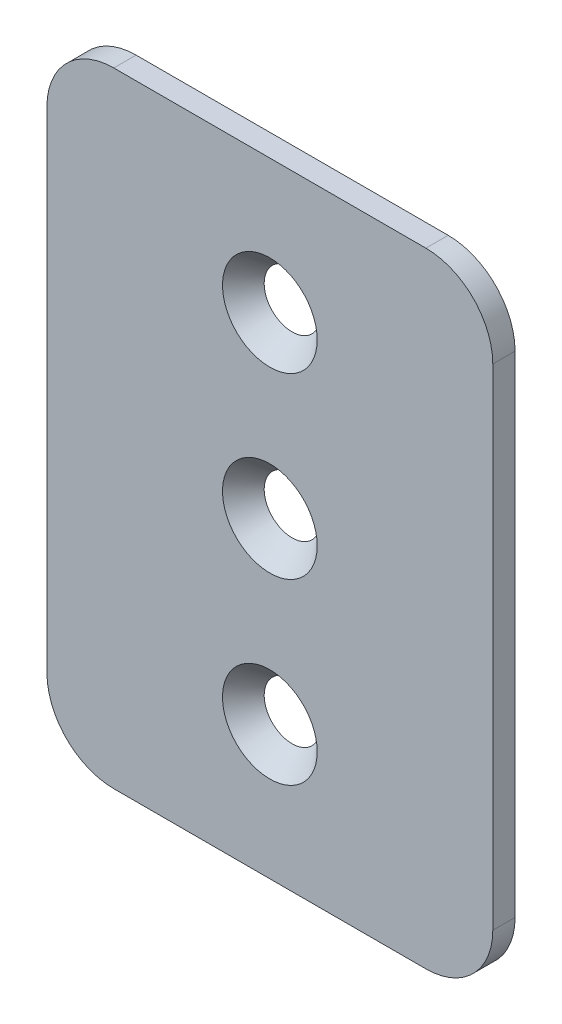
from build123d import *

# Parameters (mm, degrees)
SKETCH1_R                                    = 2.5527
BOSS_EXTRUDE1_DEPTH                          = 3.175
CSK_FOR_1_4_FLAT_HEAD_SOCKET_CAP_SCR_2_COUNT = 2
CSK_FOR_1_4_FLAT_HEAD_SOCKET_CAP_SCR_2_PITCH = 25.4
CSK_FOR_1_4_FLAT_HEAD_SOCKET_CAP_SCR_3_COUNT = 2
CSK_FOR_1_4_FLAT_HEAD_SOCKET_CAP_SCR_3_PITCH = 50.8


with BuildPart() as part:
    # Sketch1 → Boss-Extrude1 (new body)
    with BuildSketch(Plane.XY):
        with BuildLine():
            Line((-22.225, 44.45), (22.225, 44.45))
            ThreePointArc((22.225, 44.45), (28.960192091, 41.660192091), (31.75, 34.925))
            Line((31.75, 34.925), (31.75, -34.925))
            ThreePointArc((31.75, -34.925), (28.960192091, -41.660192091), (22.225, -44.45))
            Line((22.225, -44.45), (-22.225, -44.45))
            ThreePointArc((-22.225, -44.45), (-28.960192091, -41.660192091), (-31.75, -34.925))
            Line((-31.75, -34.925), (-31.75, 34.925))
            ThreePointArc((-31.75, 34.925), (-28.960192091, 41.660192091), (-22.225, 44.45))
        make_face()
        with Locations((0, 25.4)):
            Circle(SKETCH1_R, mode=Mode.SUBTRACT)
        Circle(SKETCH1_R, mode=Mode.SUBTRACT)
        with Locations((0, -25.4)):
            Circle(SKETCH1_R, mode=Mode.SUBTRACT)
    extrude(amount=BOSS_EXTRUDE1_DEPTH)

    # Sketch2 → CSK for 1/4 Flat Head Socket Cap Screw1 (revolve, cut)
    with BuildSketch(Plane(origin=(0, 25.4, 3.175), x_dir=(0, -1, 0), z_dir=(1, 0, 0))):
        Polygon((0, 0), (0, 3.175), (3.3782, 3.175), (3.3782, 3.871564875), (6.7437, 0), align=None)
    csk_for_1_4_flat_head_socket_cap_screw1 = revolve(axis=Axis((0, 25.4, 9.525), (0, 0, -1)), mode=Mode.SUBTRACT)

    # CSK for 1_4 Flat Head Socket Cap Scr 2: CSK for 1/4 Flat Head Socket Cap Screw1 ×2
    with Locations(*[(0, -i * CSK_FOR_1_4_FLAT_HEAD_SOCKET_CAP_SCR_2_PITCH, 0) for i in range(1, CSK_FOR_1_4_FLAT_HEAD_SOCKET_CAP_SCR_2_COUNT)]):
        add(csk_for_1_4_flat_head_socket_cap_screw1, mode=Mode.SUBTRACT)

    # CSK for 1_4 Flat Head Socket Cap Scr 3: CSK for 1/4 Flat Head Socket Cap Screw1 ×2
    with Locations(*[(0, -i * CSK_FOR_1_4_FLAT_HEAD_SOCKET_CAP_SCR_3_PITCH, 0) for i in range(1, CSK_FOR_1_4_FLAT_HEAD_SOCKET_CAP_SCR_3_COUNT)]):
        add(csk_for_1_4_flat_head_socket_cap_screw1, mode=Mode.SUBTRACT)


solid = part.part
